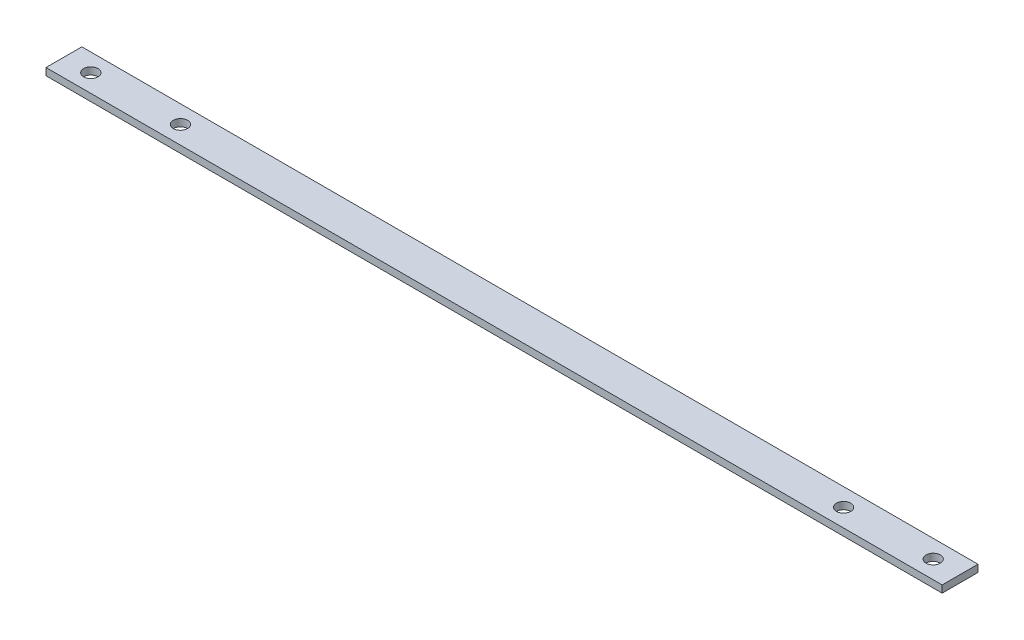
from build123d import *

# Parameters (mm, degrees)
SKETCH_1_W          = 20
SKETCH_1_H          = 4
EXTRUDE_1_DEPTH     = 500
SKETCH_2_R          = 4
CUT_EXTRUDE_1_DEPTH = 5


with BuildPart() as part:
    # Эскиз1 → Вытянуть-Тонкостенный1 (new body)
    with BuildSketch(Plane(origin=(0, 0, 0), x_dir=(0, 0, -1), z_dir=(1, 0, 0))):
        with Locations((10, -2)):
            Rectangle(SKETCH_1_W, SKETCH_1_H)
    extrude(amount=EXTRUDE_1_DEPTH)

    # Эскиз2 → Вырез-Вытянуть1 (cut, through all)
    with BuildSketch(Plane(origin=(0, 0, 0), x_dir=(1, 0, 0), z_dir=(0, 1, 0))):
        with Locations((15, 10)):
            Circle(SKETCH_2_R)
        with Locations((65, 10)):
            Circle(SKETCH_2_R)
        with Locations((435, 10)):
            Circle(SKETCH_2_R)
        with Locations((485, 10)):
            Circle(SKETCH_2_R)
    extrude(amount=-CUT_EXTRUDE_1_DEPTH, mode=Mode.SUBTRACT)


solid = part.part
